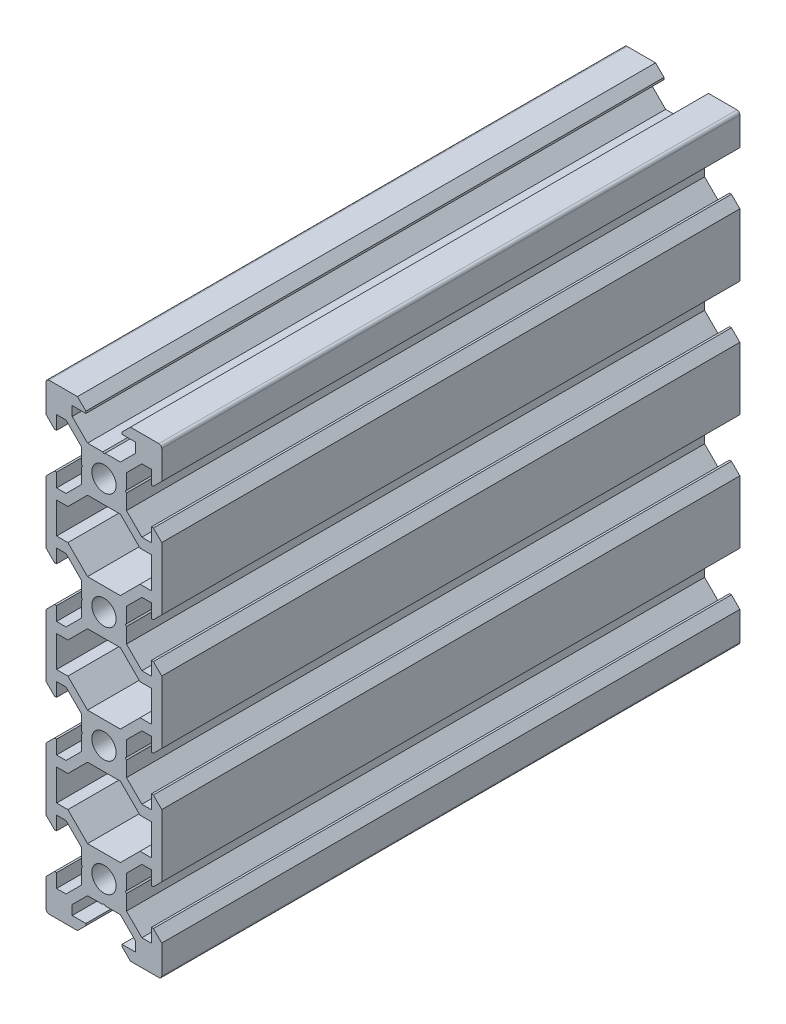
from build123d import *

# Parameters (mm, degrees)
SKETCH1_R           = 2.1
BOSS_EXTRUDE1_DEPTH = 100


with BuildPart() as part:
    # Sketch1 → Boss-Extrude1 (new body)
    with BuildSketch(Plane.XY):
        with BuildLine():
            Line((4.58, -40), (9.5, -40))
            ThreePointArc((9.5, -40), (9.853553391, -39.853553391), (10, -39.5))
            Line((10, -39.5), (10, -34.58))
            Line((10, -34.58), (8.545, -33.125))
            Line((8.545, -33.125), (8.2, -33.125))
            Line((8.2, -33.125), (8.2, -35.5))
            Line((8.2, -35.5), (6.560660172, -35.5))
            Line((6.560660172, -35.5), (3.9, -32.839339828))
            Line((3.9, -32.839339828), (3.9, -30.21))
            Line((3.9, -30.21), (3.69, -30))
            Line((3.69, -30), (3.9, -29.79))
            Line((3.9, -29.79), (3.9, -27.160660172))
            Line((3.9, -27.160660172), (6.560660172, -24.5))
            Line((6.560660172, -24.5), (8.2, -24.5))
            Line((8.2, -24.5), (8.2, -26.875))
            Line((8.2, -26.875), (8.545, -26.875))
            Line((8.545, -26.875), (10, -25.42))
            Line((10, -25.42), (10, -14.58))
            Line((10, -14.58), (8.545, -13.125))
            Line((8.545, -13.125), (8.2, -13.125))
            Line((8.2, -13.125), (8.2, -15.5))
            Line((8.2, -15.5), (6.560660172, -15.5))
            Line((6.560660172, -15.5), (3.9, -12.839339828))
            Line((3.9, -12.839339828), (3.9, -10.21))
            Line((3.9, -10.21), (3.69, -10))
            Line((3.69, -10), (3.9, -9.79))
            Line((3.9, -9.79), (3.9, -7.160660172))
            Line((3.9, -7.160660172), (6.560660172, -4.5))
            Line((6.560660172, -4.5), (8.2, -4.5))
            Line((8.2, -4.5), (8.2, -6.875))
            Line((8.2, -6.875), (8.545, -6.875))
            Line((8.545, -6.875), (10, -5.42))
            Line((10, -5.42), (10, 5.42))
            Line((10, 5.42), (8.545, 6.875))
            Line((8.545, 6.875), (8.2, 6.875))
            Line((8.2, 6.875), (8.2, 4.5))
            Line((8.2, 4.5), (6.560660172, 4.5))
            Line((6.560660172, 4.5), (3.9, 7.160660172))
            Line((3.9, 7.160660172), (3.9, 9.79))
            Line((3.9, 9.79), (3.69, 10))
            Line((3.69, 10), (3.9, 10.21))
            Line((3.9, 10.21), (3.9, 12.839339828))
            Line((3.9, 12.839339828), (6.560660172, 15.5))
            Line((6.560660172, 15.5), (8.2, 15.5))
            Line((8.2, 15.5), (8.2, 13.125))
            Line((8.2, 13.125), (8.545, 13.125))
            Line((8.545, 13.125), (10, 14.58))
            Line((10, 14.58), (10, 25.42))
            Line((10, 25.42), (8.545, 26.875))
            Line((8.545, 26.875), (8.2, 26.875))
            Line((8.2, 26.875), (8.2, 24.5))
            Line((8.2, 24.5), (6.560660172, 24.5))
            Line((6.560660172, 24.5), (3.9, 27.160660172))
            Line((3.9, 27.160660172), (3.9, 29.79))
            Line((3.9, 29.79), (3.69, 30))
            Line((3.69, 30), (3.9, 30.21))
            Line((3.9, 30.21), (3.9, 32.839339828))
            Line((3.9, 32.839339828), (6.560660172, 35.5))
            Line((6.560660172, 35.5), (8.2, 35.5))
            Line((8.2, 35.5), (8.2, 33.125))
            Line((8.2, 33.125), (8.545, 33.125))
            Line((8.545, 33.125), (10, 34.58))
            Line((10, 34.58), (10, 39.5))
            ThreePointArc((10, 39.5), (9.853553391, 39.853553391), (9.5, 40))
            Line((9.5, 40), (4.58, 40))
            Line((4.58, 40), (3.125, 38.545))
            Line((3.125, 38.545), (3.125, 38.2))
            Line((3.125, 38.2), (5.5, 38.2))
            Line((5.5, 38.2), (5.5, 36.560660172))
            Line((5.5, 36.560660172), (2.839339828, 33.9))
            Line((2.839339828, 33.9), (0.21, 33.9))
            Line((0.21, 33.9), (0, 33.69))
            Line((0, 33.69), (-0.21, 33.9))
            Line((-0.21, 33.9), (-2.839339828, 33.9))
            Line((-2.839339828, 33.9), (-5.5, 36.560660172))
            Line((-5.5, 36.560660172), (-5.5, 38.2))
            Line((-5.5, 38.2), (-3.125, 38.2))
            Line((-3.125, 38.2), (-3.125, 38.545))
            Line((-3.125, 38.545), (-4.58, 40))
            Line((-4.58, 40), (-9.5, 40))
            ThreePointArc((-9.5, 40), (-9.853553391, 39.853553391), (-10, 39.5))
            Line((-10, 39.5), (-10, 34.58))
            Line((-10, 34.58), (-8.545, 33.125))
            Line((-8.545, 33.125), (-8.2, 33.125))
            Line((-8.2, 33.125), (-8.2, 35.5))
            Line((-8.2, 35.5), (-6.560660172, 35.5))
            Line((-6.560660172, 35.5), (-3.9, 32.839339828))
            Line((-3.9, 32.839339828), (-3.9, 30.21))
            Line((-3.9, 30.21), (-3.69, 30))
            Line((-3.69, 30), (-3.9, 29.79))
            Line((-3.9, 29.79), (-3.9, 27.160660172))
            Line((-3.9, 27.160660172), (-6.560660172, 24.5))
            Line((-6.560660172, 24.5), (-8.2, 24.5))
            Line((-8.2, 24.5), (-8.2, 26.875))
            Line((-8.2, 26.875), (-8.545, 26.875))
            Line((-8.545, 26.875), (-10, 25.42))
            Line((-10, 25.42), (-10, 14.58))
            Line((-10, 14.58), (-8.545, 13.125))
            Line((-8.545, 13.125), (-8.2, 13.125))
            Line((-8.2, 13.125), (-8.2, 15.5))
            Line((-8.2, 15.5), (-6.560660172, 15.5))
            Line((-6.560660172, 15.5), (-3.9, 12.839339828))
            Line((-3.9, 12.839339828), (-3.9, 10.21))
            Line((-3.9, 10.21), (-3.69, 10))
            Line((-3.69, 10), (-3.9, 9.79))
            Line((-3.9, 9.79), (-3.9, 7.160660172))
            Line((-3.9, 7.160660172), (-6.560660172, 4.5))
            Line((-6.560660172, 4.5), (-8.2, 4.5))
            Line((-8.2, 4.5), (-8.2, 6.875))
            Line((-8.2, 6.875), (-8.545, 6.875))
            Line((-8.545, 6.875), (-10, 5.42))
            Line((-10, 5.42), (-10, -5.42))
            Line((-10, -5.42), (-8.545, -6.875))
            Line((-8.545, -6.875), (-8.2, -6.875))
            Line((-8.2, -6.875), (-8.2, -4.5))
            Line((-8.2, -4.5), (-6.560660172, -4.5))
            Line((-6.560660172, -4.5), (-3.9, -7.160660172))
            Line((-3.9, -7.160660172), (-3.9, -9.79))
            Line((-3.9, -9.79), (-3.69, -10))
            Line((-3.69, -10), (-3.9, -10.21))
            Line((-3.9, -10.21), (-3.9, -12.839339828))
            Line((-3.9, -12.839339828), (-6.560660172, -15.5))
            Line((-6.560660172, -15.5), (-8.2, -15.5))
            Line((-8.2, -15.5), (-8.2, -13.125))
            Line((-8.2, -13.125), (-8.545, -13.125))
            Line((-8.545, -13.125), (-10, -14.58))
            Line((-10, -14.58), (-10, -25.42))
            Line((-10, -25.42), (-8.545, -26.875))
            Line((-8.545, -26.875), (-8.2, -26.875))
            Line((-8.2, -26.875), (-8.2, -24.5))
            Line((-8.2, -24.5), (-6.560660172, -24.5))
            Line((-6.560660172, -24.5), (-3.9, -27.160660172))
            Line((-3.9, -27.160660172), (-3.9, -29.79))
            Line((-3.9, -29.79), (-3.69, -30))
            Line((-3.69, -30), (-3.9, -30.21))
            Line((-3.9, -30.21), (-3.9, -32.839339828))
            Line((-3.9, -32.839339828), (-6.560660172, -35.5))
            Line((-6.560660172, -35.5), (-8.2, -35.5))
            Line((-8.2, -35.5), (-8.2, -33.125))
            Line((-8.2, -33.125), (-8.545, -33.125))
            Line((-8.545, -33.125), (-10, -34.58))
            Line((-10, -34.58), (-10, -39.5))
            ThreePointArc((-10, -39.5), (-9.853553391, -39.853553391), (-9.5, -40))
            Line((-9.5, -40), (-4.58, -40))
            Line((-4.58, -40), (-3.125, -38.545))
            Line((-3.125, -38.545), (-3.125, -38.2))
            Line((-3.125, -38.2), (-5.5, -38.2))
            Line((-5.5, -38.2), (-5.5, -36.560660172))
            Line((-5.5, -36.560660172), (-2.839339828, -33.9))
            Line((-2.839339828, -33.9), (-0.21, -33.9))
            Line((-0.21, -33.9), (0, -33.69))
            Line((0, -33.69), (0.21, -33.9))
            Line((0.21, -33.9), (2.839339828, -33.9))
            Line((2.839339828, -33.9), (5.5, -36.560660172))
            Line((5.5, -36.560660172), (5.5, -38.2))
            Line((5.5, -38.2), (3.125, -38.2))
            Line((3.125, -38.2), (3.125, -38.545))
            Line((3.125, -38.545), (4.58, -40))
        make_face()
        with Locations((0, -30)):
            Circle(SKETCH1_R, mode=Mode.SUBTRACT)
        Polygon((-6.239339828, -22.7), (-8.2, -22.7), (-8.2, -17.3), (-6.239339828, -17.3), (-2.839339828, -13.9), (2.839339828, -13.9), (6.239339828, -17.3), (8.2, -17.3), (8.2, -22.7), (6.239339828, -22.7), (2.839339828, -26.1), (-2.839339828, -26.1), align=None, mode=Mode.SUBTRACT)
        with Locations((0, -10)):
            Circle(SKETCH1_R, mode=Mode.SUBTRACT)
        Polygon((-6.239339828, -2.7), (-8.2, -2.7), (-8.2, 2.7), (-6.239339828, 2.7), (-2.839339828, 6.1), (2.839339828, 6.1), (6.239339828, 2.7), (8.2, 2.7), (8.2, -2.7), (6.239339828, -2.7), (2.839339828, -6.1), (-2.839339828, -6.1), align=None, mode=Mode.SUBTRACT)
        with Locations((0, 10)):
            Circle(SKETCH1_R, mode=Mode.SUBTRACT)
        Polygon((-6.239339828, 17.3), (-8.2, 17.3), (-8.2, 22.7), (-6.239339828, 22.7), (-2.839339828, 26.1), (2.839339828, 26.1), (6.239339828, 22.7), (8.2, 22.7), (8.2, 17.3), (6.239339828, 17.3), (2.839339828, 13.9), (-2.839339828, 13.9), align=None, mode=Mode.SUBTRACT)
        with Locations((0, 30)):
            Circle(SKETCH1_R, mode=Mode.SUBTRACT)
    extrude(amount=BOSS_EXTRUDE1_DEPTH)


solid = part.part
